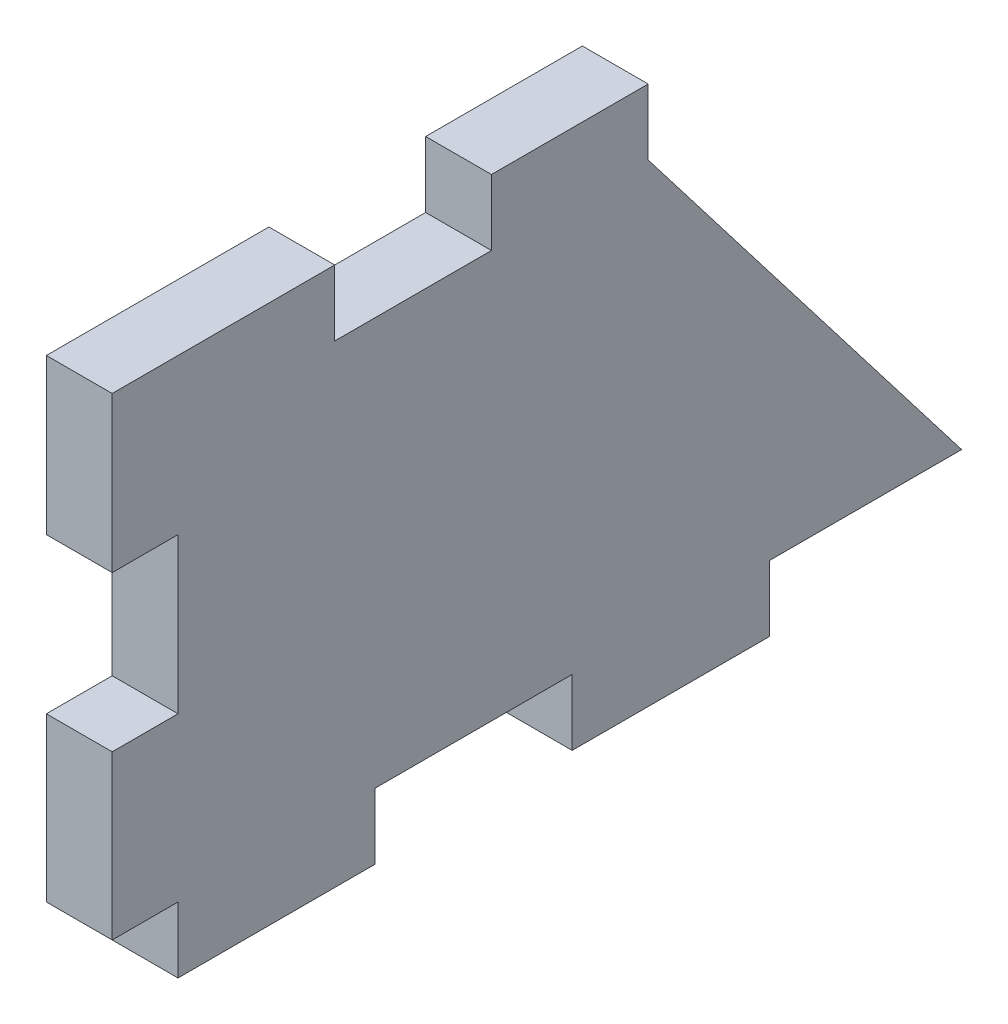
from build123d import *

# Parameters (mm, degrees)
SKETCH1_W            = 63.5
SKETCH1_H            = 33.02
BOSS_EXTRUDE1_DEPTH  = 5.334
CUT_EXTRUDE1_DEPTH   = 6.334
SKETCH3_W            = 12.7
SKETCH3_H            = 5.334
SKETCH3_W_2          = 15.971321783
BOSS_EXTRUDE2_DEPTH  = 5.334
SKETCH4_W            = 5.334
SKETCH4_H            = 37.084
BOSS_EXTRUDE7_DEPTH  = 5.334
SKETCH5_W            = 5.334
SKETCH5_H            = 12.573
CUT_EXTRUDE2_DEPTH   = 6.334
SKETCH6_W            = 5.334
SKETCH6_H            = 0.635
BOSS_EXTRUDE9_DEPTH  = 5.334
SKETCH7_W            = 5.334
SKETCH7_H            = 0.635
BOSS_EXTRUDE10_DEPTH = 5.334


with BuildPart() as part:
    # Sketch1 → Boss-Extrude1 (new body)
    with BuildSketch(Plane(origin=(0, 0, 0), x_dir=(0, 0, -1), z_dir=(1, 0, 0))):
        Rectangle(SKETCH1_W, SKETCH1_H)
    extrude(amount=BOSS_EXTRUDE1_DEPTH)

    # Sketch2 → Cut-Extrude1 (cut, through all)
    with BuildSketch(Plane.ZY):
        Polygon((-31.75, -16.51), (-31.75, 16.51), (-6.35, 16.51), align=None)
    extrude(amount=-CUT_EXTRUDE1_DEPTH, mode=Mode.SUBTRACT)

    # Sketch3 → Boss-Extrude2 (add, through all)
    with BuildSketch(Plane.ZY):
        with Locations((25.4, 19.177)):
            Rectangle(SKETCH3_W, SKETCH3_H)
        with Locations((0, 19.177)):
            Rectangle(SKETCH3_W, SKETCH3_H)
        with Locations((23.764339109, -19.177)):
            Rectangle(SKETCH3_W_2, SKETCH3_H)
        with Locations((-8.178304458, -19.177)):
            Rectangle(SKETCH3_W_2, SKETCH3_H)
    extrude(amount=-BOSS_EXTRUDE2_DEPTH)

    # Sketch4 → Boss-Extrude7 (add)
    with BuildSketch(Plane.ZY):
        with Locations((34.417, 2.667)):
            Rectangle(SKETCH4_W, SKETCH4_H)
    extrude(amount=-BOSS_EXTRUDE7_DEPTH)

    # Sketch5 → Cut-Extrude2 (cut, through all)
    with BuildSketch(Plane(origin=(5.334, 0, 0), x_dir=(0, 0, -1), z_dir=(1, 0, 0))):
        with Locations((-34.417, 2.9845)):
            Rectangle(SKETCH5_W, SKETCH5_H)
    extrude(amount=-CUT_EXTRUDE2_DEPTH, mode=Mode.SUBTRACT)

    # Sketch6 → Boss-Extrude9 (add)
    with BuildSketch(Plane(origin=(5.334, 0, 0), x_dir=(0, 0, -1), z_dir=(1, 0, 0))):
        with Locations((-34.417, 21.5265)):
            Rectangle(SKETCH6_W, SKETCH6_H)
    extrude(amount=-BOSS_EXTRUDE9_DEPTH)

    # Sketch7 → Boss-Extrude10 (add)
    with BuildSketch(Plane(origin=(5.334, 0, 0), x_dir=(0, 0, -1), z_dir=(1, 0, 0))):
        with Locations((-34.417, -16.1925)):
            Rectangle(SKETCH7_W, SKETCH7_H)
    extrude(amount=-BOSS_EXTRUDE10_DEPTH)


solid = part.part
